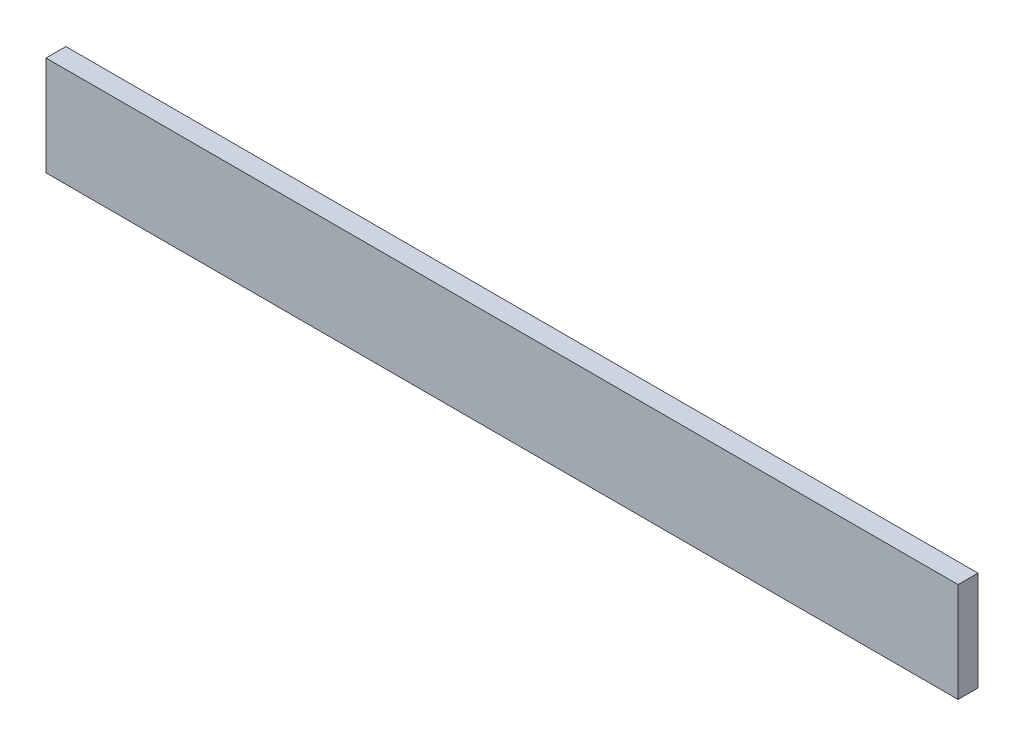
from build123d import *

# Parameters (mm, degrees)
SKETCH_1_W      = 458.407253026
SKETCH_1_H      = 50
EXTRUDE_1_DEPTH = 10


with BuildPart() as part:
    # Эскиз1 → Бобышка-Вытянуть1 (new body)
    with BuildSketch(Plane.XY):
        with Locations((229.203626513, 25)):
            Rectangle(SKETCH_1_W, SKETCH_1_H)
    extrude(amount=EXTRUDE_1_DEPTH)


solid = part.part
